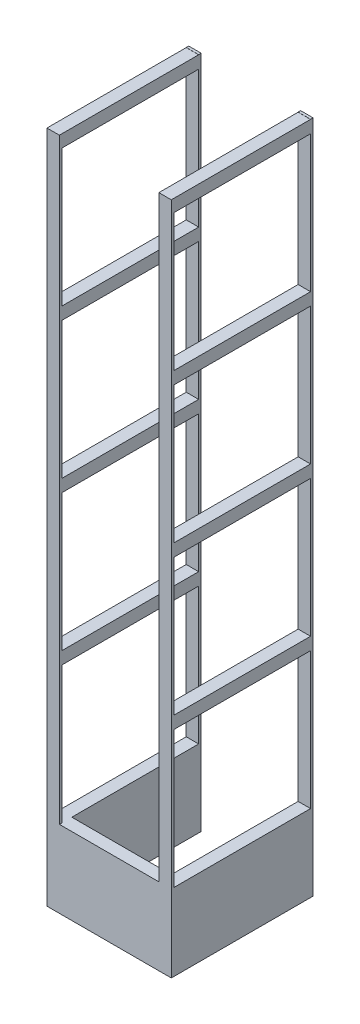
from build123d import *

# Parameters (mm, degrees)
SKETCH1_W            = 10
SKETCH1_H            = 2
BOSS_EXTRUDE1_DEPTH  = 112
SKETCH2_W            = 10
SKETCH2_H            = 2
BOSS_EXTRUDE2_DEPTH  = 480
SKETCH3_W            = 10
SKETCH3_H            = 2
BOSS_EXTRUDE3_DEPTH  = 90
SKETCH4_W            = 10
SKETCH4_H            = 2
BOSS_EXTRUDE4_DEPTH  = 102
SKETCH5_W            = 10
SKETCH5_H            = 2
BOSS_EXTRUDE5_DEPTH  = 480
SKETCH6_W            = 10
SKETCH6_H            = 10
BOSS_EXTRUDE6_DEPTH  = 110
SKETCH7_W            = 10
SKETCH7_H            = 10
BOSS_EXTRUDE7_DEPTH  = 110
SKETCH8_W            = 10
SKETCH8_H            = 10
BOSS_EXTRUDE8_DEPTH  = 110
SKETCH9_W            = 10
SKETCH9_H            = 10
BOSS_EXTRUDE9_DEPTH  = 110
BOSS_EXTRUDE10_DEPTH = 60
SKETCH12_W           = 10
SKETCH12_H           = 2
BOSS_EXTRUDE11_DEPTH = 542.116195333


with BuildPart() as part:
    # Sketch1 → Boss-Extrude1 (new body)
    with BuildSketch(Plane.XY):
        Rectangle(SKETCH1_W, SKETCH1_H)
    extrude(amount=BOSS_EXTRUDE1_DEPTH)

    # Sketch2 → Boss-Extrude2 (add)
    with BuildSketch(Plane(origin=(0, 1, 0), x_dir=(1, 0, 0), z_dir=(0, 1, 0))):
        with Locations((0, -111)):
            Rectangle(SKETCH2_W, SKETCH2_H)
    extrude(amount=BOSS_EXTRUDE2_DEPTH)

    # Sketch3 → Boss-Extrude3 (add)
    with BuildSketch(Plane(origin=(5, 0, 0), x_dir=(0, 0, -1), z_dir=(1, 0, 0))):
        with Locations((-107, 0)):
            Rectangle(SKETCH3_W, SKETCH3_H)
    extrude(amount=BOSS_EXTRUDE3_DEPTH)

    # Sketch4 → Boss-Extrude4 (add)
    with BuildSketch(Plane(origin=(0, 0, 102), x_dir=(-1, 0, 0), z_dir=(0, 0, -1))):
        with Locations((-90, 0)):
            Rectangle(SKETCH4_W, SKETCH4_H)
    extrude(amount=BOSS_EXTRUDE4_DEPTH)

    # Sketch5 → Boss-Extrude5 (add)
    with BuildSketch(Plane(origin=(0, 1, 0), x_dir=(1, 0, 0), z_dir=(0, 1, 0))):
        with Locations((90, -111)):
            Rectangle(SKETCH5_W, SKETCH5_H)
    extrude(amount=BOSS_EXTRUDE5_DEPTH)

    # Sketch6 → Boss-Extrude6 (add)
    with BuildSketch(Plane(origin=(0, 0, 110), x_dir=(-1, 0, 0), z_dir=(0, 0, -1))):
        with Locations((-90, 116)):
            Rectangle(SKETCH6_W, SKETCH6_H)
        with Locations((0, 116)):
            Rectangle(SKETCH6_W, SKETCH6_H)
    extrude(amount=BOSS_EXTRUDE6_DEPTH)

    # Sketch7 → Boss-Extrude7 (add)
    with BuildSketch(Plane(origin=(0, 0, 110), x_dir=(-1, 0, 0), z_dir=(0, 0, -1))):
        with Locations((-90, 236)):
            Rectangle(SKETCH7_W, SKETCH7_H)
        with Locations((0, 236)):
            Rectangle(SKETCH7_W, SKETCH7_H)
    extrude(amount=BOSS_EXTRUDE7_DEPTH)

    # Sketch8 → Boss-Extrude8 (add)
    with BuildSketch(Plane(origin=(0, 0, 110), x_dir=(-1, 0, 0), z_dir=(0, 0, -1))):
        with Locations((-90, 356)):
            Rectangle(SKETCH8_W, SKETCH8_H)
        with Locations((0, 356)):
            Rectangle(SKETCH8_W, SKETCH8_H)
    extrude(amount=BOSS_EXTRUDE8_DEPTH)

    # Sketch9 → Boss-Extrude9 (add)
    with BuildSketch(Plane(origin=(0, 0, 110), x_dir=(-1, 0, 0), z_dir=(0, 0, -1))):
        with Locations((-90, 476)):
            Rectangle(SKETCH9_W, SKETCH9_H)
        with Locations((0, 476)):
            Rectangle(SKETCH9_W, SKETCH9_H)
    extrude(amount=BOSS_EXTRUDE9_DEPTH)

    # Sketch11 → Boss-Extrude10 (add)
    with BuildSketch(Plane.XZ.offset(1)):
        Polygon((-5, 112), (-5, 0), (5, 0), (5, 102), (85, 102), (85, 0), (95, 0), (95, 112), align=None)
    extrude(amount=BOSS_EXTRUDE10_DEPTH)

    # Sketch12 → Boss-Extrude11 (add)
    with BuildSketch(Plane.XZ.offset(61)):
        with Locations((90, -1)):
            Rectangle(SKETCH12_W, SKETCH12_H)
        with Locations((0, -1)):
            Rectangle(SKETCH12_W, SKETCH12_H)
    extrude(amount=-BOSS_EXTRUDE11_DEPTH)


solid = part.part
